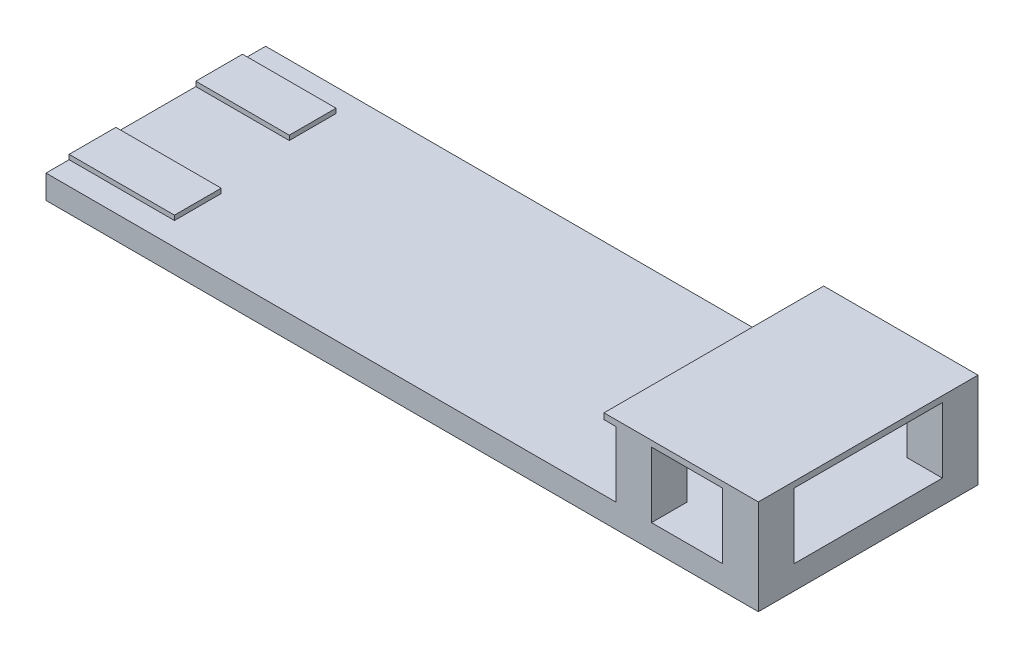
from build123d import *

# Parameters (mm, degrees)
SKETCH1_W           = 762
SKETCH1_H           = 234.95
BOSS_EXTRUDE1_DEPTH = 12.7
SKETCH2_W           = 38.1
SKETCH2_H           = 38.1
BOSS_EXTRUDE2_DEPTH = 70
SKETCH3_W           = 165.1
SKETCH3_H           = 234.95
BOSS_EXTRUDE3_DEPTH = 6.35
SKETCH4_W           = 100
SKETCH4_H           = 50
SKETCH4_W_2         = 112.7
BOSS_EXTRUDE4_DEPTH = 5


with BuildPart() as part:
    # Sketch1 → Boss-Extrude1 (new body, symmetric)
    with BuildSketch(Plane(origin=(0, 0, 0), x_dir=(1, 0, 0), z_dir=(0, 1, 0))):
        with Locations((192.9, 0)):
            Rectangle(SKETCH1_W, SKETCH1_H)
    extrude(amount=BOSS_EXTRUDE1_DEPTH, both=True)

    # Sketch2 → Boss-Extrude2 (add)
    with BuildSketch(Plane(origin=(0, 12.7, 0), x_dir=(1, 0, 0), z_dir=(0, 1, 0))):
        with Locations((554.85, 98.425)):
            Rectangle(SKETCH2_W, SKETCH2_H)
        with Locations((554.85, -98.425)):
            Rectangle(SKETCH2_W, SKETCH2_H)
        with Locations((440.55, -98.425)):
            Rectangle(SKETCH2_W, SKETCH2_H)
        with Locations((440.55, 98.425)):
            Rectangle(SKETCH2_W, SKETCH2_H)
    extrude(amount=BOSS_EXTRUDE2_DEPTH)

    # Sketch3 → Boss-Extrude3 (add)
    with BuildSketch(Plane(origin=(0, 82.7, 0), x_dir=(1, 0, 0), z_dir=(0, 1, 0))):
        with Locations((491.35, 0)):
            Rectangle(SKETCH3_W, SKETCH3_H)
    extrude(amount=BOSS_EXTRUDE3_DEPTH)

    # Sketch4 → Boss-Extrude4 (add)
    with BuildSketch(Plane(origin=(0, 12.7, 0), x_dir=(1, 0, 0), z_dir=(0, 1, 0))):
        with Locations((-138.1, 67.75)):
            Rectangle(SKETCH4_W, SKETCH4_H)
        with Locations((-131.75, -67.75)):
            Rectangle(SKETCH4_W_2, SKETCH4_H)
    extrude(amount=BOSS_EXTRUDE4_DEPTH)


solid = part.part
